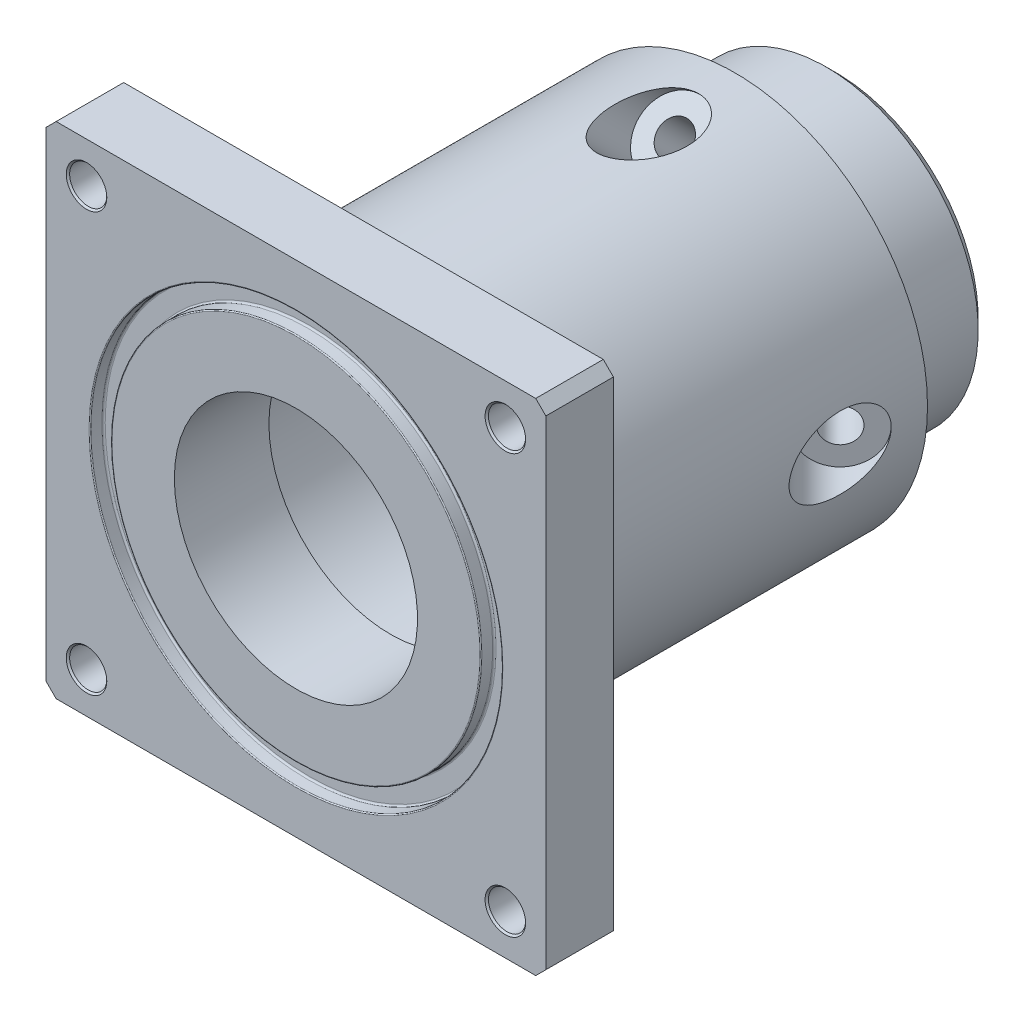
from build123d import *

# Parameters (mm, degrees)
FURO_COM_FOLGA_DE_M51_D           = 5.5
FURO_COM_FOLGA_DE_M51_CSINK_D     = 6
FURO_COM_FOLGA_DE_M51_CSINK_ANGLE = 90
ESBO_O8_R                         = 52.5
ESBO_O8_W                         = 74
ESBO_O8_H                         = 74
CORTE_EXTRUS_O1_DEPTH             = 81
PADR_OCIRCULAR1_COUNT             = 4
CHANFRO1_SIZE                     = 1.5
ESBO_O35_W                        = 3.1
ESBO_O35_H                        = 2
FILETE1_R                         = 0.25
FILETE2_R                         = 0.15
CHANFRO2_SIZE                     = 1.5
FILETE3_R                         = 1


with BuildPart() as part:
    # Esboço2 → Revolução1 (revolve)
    with BuildSketch(Plane(origin=(0, 0, 0), x_dir=(0, 0, -1), z_dir=(1, 0, 0))):
        Polygon((0, 20), (0, 52.5), (10, 52.5), (10, 28.5), (65, 28.5), (65, 22.5), (65, 21), (68, 21), (68, 22.5), (80, 22.5), (80, 20), (14, 20), (14, 18), (0, 18), align=None)
    revolve(axis=Axis((0, 0, -80), (0, 0, 1)))

    # Furo com folga de M51 (through all)
    with Locations(Plane.XY):
        with Locations((-31, -31), (-31, 31), (31, 31), (31, -31)):
            CounterSinkHole(FURO_COM_FOLGA_DE_M51_D / 2, FURO_COM_FOLGA_DE_M51_CSINK_D / 2, counter_sink_angle=FURO_COM_FOLGA_DE_M51_CSINK_ANGLE)

    # Esboço8 → Corte-extrusão1 (cut, through all)
    with BuildSketch(Plane.XY):
        Circle(ESBO_O8_R)
        Rectangle(ESBO_O8_W, ESBO_O8_H, mode=Mode.SUBTRACT)
    extrude(amount=-CORTE_EXTRUS_O1_DEPTH, mode=Mode.SUBTRACT)

    # Esboço33 → Corte-Revolução1 (revolve, cut)
    with BuildSketch(Plane(origin=(0, 0, 0), x_dir=(1, 0, 0), z_dir=(0, 1, 0))):
        Polygon((-22.712824205, 54.321772669), (-20.697569878, 52.306518343), (-31.997290029, 41.006798193), (-31.997290029, 48.572840752), (-17.57013078, 63), (-15.802363827, 61.232233047), align=None)
    corte_revolu_o1 = revolve(axis=Axis((-31.997290029, 0, -48.572840752), (0.707106781, 0, -0.707106781)), mode=Mode.SUBTRACT)

    # PadrãoCircular1: Corte-Revolução1 ×4 about axis
    padr_ocircular1_axis = Axis((0, 0, 0), (0, 0, 1))
    for i in range(1, PADR_OCIRCULAR1_COUNT):
        add(corte_revolu_o1.rotate(padr_ocircular1_axis, i * 360 / PADR_OCIRCULAR1_COUNT), mode=Mode.SUBTRACT)

    # Chanfro1
    chanfro1_edges = [part.edges().sort_by_distance(p)[0] for p in [
        (0, -22.5, -80),
    ]]
    chamfer(chanfro1_edges, length=CHANFRO1_SIZE)

    # Esboço35 → Corte-Revolução2 (revolve, cut)
    with BuildSketch(Plane(origin=(0, 0, 0), x_dir=(1, 0, 0), z_dir=(0, 1, 0))):
        with Locations((28.935, 1)):
            Rectangle(ESBO_O35_W, ESBO_O35_H)
    revolve(axis=Axis((0, 0, 0), (0, 0, -1)), mode=Mode.SUBTRACT)

    # Filete1
    filete1_edges = [part.edges().sort_by_distance(p)[0] for p in [
        (-30.485, 0, -2),
        (-27.385, 0, -2),
    ]]
    fillet(filete1_edges, radius=FILETE1_R)

    # Filete2
    filete2_edges = [part.edges().sort_by_distance(p)[0] for p in [
        (-27.385, 0, 0),
        (-30.485, 0, 0),
    ]]
    fillet(filete2_edges, radius=FILETE2_R)

    # Chanfro2
    chanfro2_edges = [part.edges().sort_by_distance(p)[0] for p in [
        (37, 37, -5),
        (37, -37, -5),
        (-37, -37, -5),
        (-37, 37, -5),
    ]]
    chamfer(chanfro2_edges, length=CHANFRO2_SIZE)

    # Filete3
    filete3_edges = [part.edges().sort_by_distance(p)[0] for p in [
        (0, -28.5, -10),
    ]]
    fillet(filete3_edges, radius=FILETE3_R)


solid = part.part
